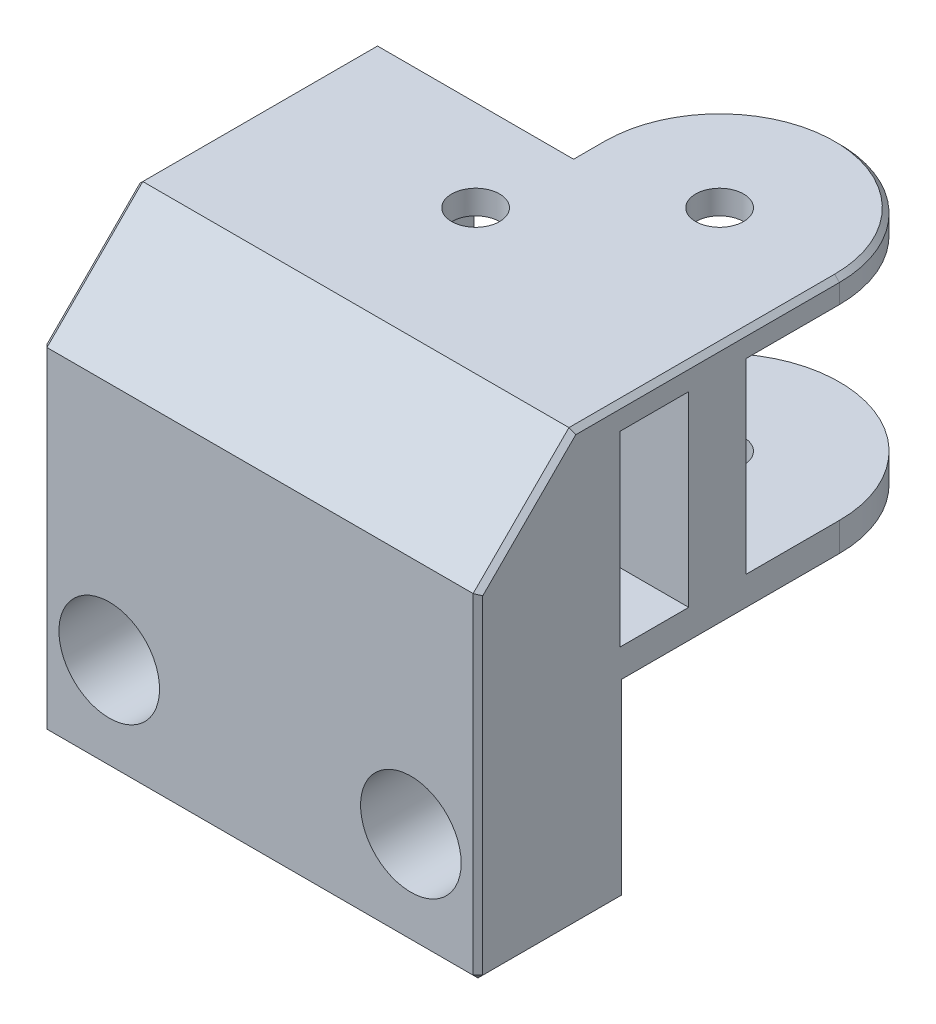
from build123d import *

# Parameters (mm, degrees)
SKETCH1_R                       = 2.5
BOSS_EXTRUDE1_DEPTH             = 25
SKETCH9_W                       = 45.48
SKETCH9_H                       = 45
BOSS_EXTRUDE4_DEPTH             = 15
CUT_EXTRUDE2_START              = -2.5
CUT_EXTRUDE2_DEPTH              = 19.5
SKETCH15_R                      = 2.5
BOSS_EXTRUDE5_DEPTH             = 25
CHAMFER1_SIZE                   = 10
CUT_EXTRUDE3_REACH              = 47.48
SKETCH16_W                      = 40
SKETCH16_H                      = 19.5
SKETCH17_W                      = 15.08
SKETCH17_H                      = 6
BOSS_EXTRUDE6_DEPTH             = 22
CBORE_FOR_M5_SBHCS1_D           = 5.5
CBORE_FOR_M5_SBHCS1_CBORE_D     = 10.5
CBORE_FOR_M5_SBHCS1_CBORE_DEPTH = 9.75
CHAMFER2_SIZE                   = 0.5


with BuildPart() as part:
    # Sketch1 → Boss-Extrude1 (new body)
    with BuildSketch(Plane(origin=(0, 0, 0), x_dir=(1, 0, 0), z_dir=(0, 1, 0))):
        Polygon((20.24, -10), (25.24, -10), (25.24, 10), (20.24, 10), (-20.24, 10), (-20.24, -10), align=None)
        Circle(SKETCH1_R, mode=Mode.SUBTRACT)
    extrude(amount=BOSS_EXTRUDE1_DEPTH)

    # Sketch9 → Boss-Extrude4 (add)
    with BuildSketch(Plane.XY.offset(10)):
        with Locations((2.5, 2.5)):
            Rectangle(SKETCH9_W, SKETCH9_H)
    extrude(amount=BOSS_EXTRUDE4_DEPTH)

    # Sketch10 → Cut-Extrude2 (cut)
    with BuildSketch(Plane(origin=(0, 25, 0), x_dir=(1, 0, 0), z_dir=(0, 1, 0)).offset(CUT_EXTRUDE2_START)):
        with BuildLine():
            Line((10.16, 0), (10.16, 10))
            Line((10.16, 10), (-10.16, 10))
            Line((-10.16, 10), (-10.16, 0))
            ThreePointArc((-10.16, 0), (0, -10.16), (10.16, 0))
        make_face()
    extrude(amount=-CUT_EXTRUDE2_DEPTH, mode=Mode.SUBTRACT)

    # Sketch15 → Boss-Extrude5 (add)
    with BuildSketch(Plane(origin=(0, 25, 0), x_dir=(1, 0, 0), z_dir=(0, 1, 0))):
        with BuildLine():
            Line((25.24, 10), (25.24, 12.732395665))
            ThreePointArc((25.24, 12.732395665), (12.732395665, 25.24), (0.224791329, 12.732395665))
            Line((0.224791329, 12.732395665), (0.224791329, 10))
            Line((0.224791329, 10), (25.24, 10))
        make_face()
        with Locations((12.732395665, 12.732395665)):
            Circle(SKETCH15_R, mode=Mode.SUBTRACT)
    extrude(amount=-BOSS_EXTRUDE5_DEPTH)

    # Chamfer1
    chamfer1_edges = [part.edges().sort_by_distance(p)[0] for p in [
        (2.5, 25, 25),
    ]]
    chamfer(chamfer1_edges, length=CHAMFER1_SIZE)

    # Sketch16 → Cut-Extrude3 (cut, up to next)
    with BuildSketch(Plane(origin=(25.24, 0, 0), x_dir=(0, 0, -1), z_dir=(1, 0, 0)), mode=Mode.PRIVATE) as cut_extrude3_sk1:
        with Locations((9.84, 12.75)):
            Rectangle(SKETCH16_W, SKETCH16_H)
    cut_extrude3_tool1 = extrude(cut_extrude3_sk1.sketch, amount=-CUT_EXTRUDE3_REACH, mode=Mode.PRIVATE) & part.part
    add(cut_extrude3_tool1.solids().sort_by_distance((25.24, 12.75, -9.84))[0], mode=Mode.SUBTRACT)

    # Sketch17 → Boss-Extrude6 (add)
    with BuildSketch(Plane(origin=(0, 25, 0), x_dir=(1, 0, 0), z_dir=(0, 1, 0))):
        with Locations((17.7, 0)):
            Rectangle(SKETCH17_W, SKETCH17_H)
    extrude(amount=-BOSS_EXTRUDE6_DEPTH)

    # CBORE for M5 SBHCS1 (through all)
    with Locations(Plane.XY.offset(25)):
        with Locations((-13.24, -10), (18.24, -10)):
            CounterBoreHole(CBORE_FOR_M5_SBHCS1_D / 2, CBORE_FOR_M5_SBHCS1_CBORE_D / 2, CBORE_FOR_M5_SBHCS1_CBORE_DEPTH)

    # Chamfer2
    chamfer2_edges = [part.edges().sort_by_distance(p)[0] for p in [
        (-20.24, 25, 2.5),
        (-20.24, -20, 17.5),
        (25.24, -20, 17.5),
        (2.5, -20, 25),
        (25.24, -2.5, 25),
        (-10.007604335, 25, -10),
        (12.732395665, 25, -25.24),
        (0.224791329, 25, -11.366197832),
        (-20.24, -2.5, 25),
        (-20.24, 20, 20),
        (25.24, 25, 1.133802168),
        (25.24, 20, 20),
    ]]
    chamfer(chamfer2_edges, length=CHAMFER2_SIZE)


solid = part.part
